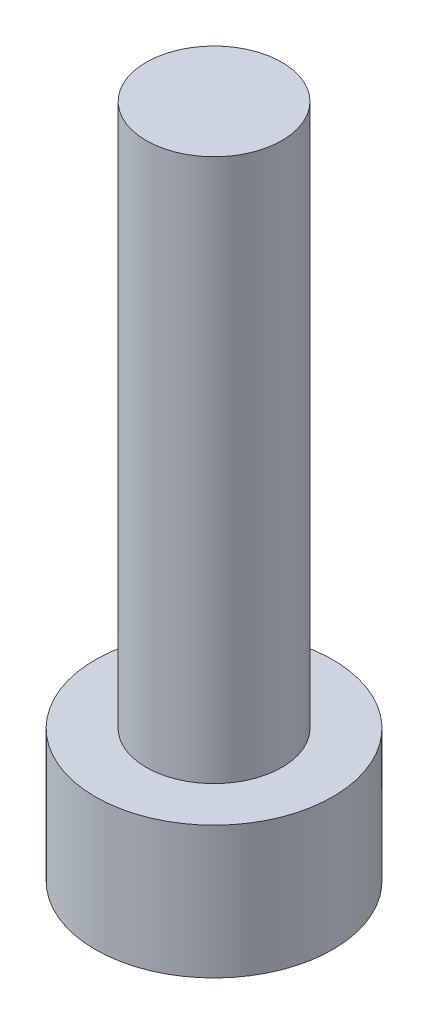
from build123d import *

# Parameters (mm, degrees)
SKETCH_1_R          = 3.5
EXTRUDE_1_DEPTH     = 3.9
SKETCH_2_R          = 2
EXTRUDE_2_DEPTH     = 16
CUT_EXTRUDE_1_DEPTH = 2.4


with BuildPart() as part:
    # 草图1 → 凸台-拉伸1 (new body)
    with BuildSketch(Plane(origin=(0, 0, 0), x_dir=(1, 0, 0), z_dir=(0, 1, 0))):
        Circle(SKETCH_1_R)
    extrude(amount=EXTRUDE_1_DEPTH)

    # 草图2 → 凸台-拉伸2 (add)
    with BuildSketch(Plane(origin=(0, 3.9, 0), x_dir=(1, 0, 0), z_dir=(0, 1, 0))):
        Circle(SKETCH_2_R)
    extrude(amount=EXTRUDE_2_DEPTH)

    # 草图3 → 切除-拉伸1 (cut)
    with BuildSketch(Plane.XZ):
        Polygon((1.725, 0), (0.8625, 1.493893822), (-0.8625, 1.493893822), (-1.725, 0), (-0.8625, -1.493893822), (0.8625, -1.493893822), align=None)
    extrude(amount=-CUT_EXTRUDE_1_DEPTH, mode=Mode.SUBTRACT)


solid = part.part
